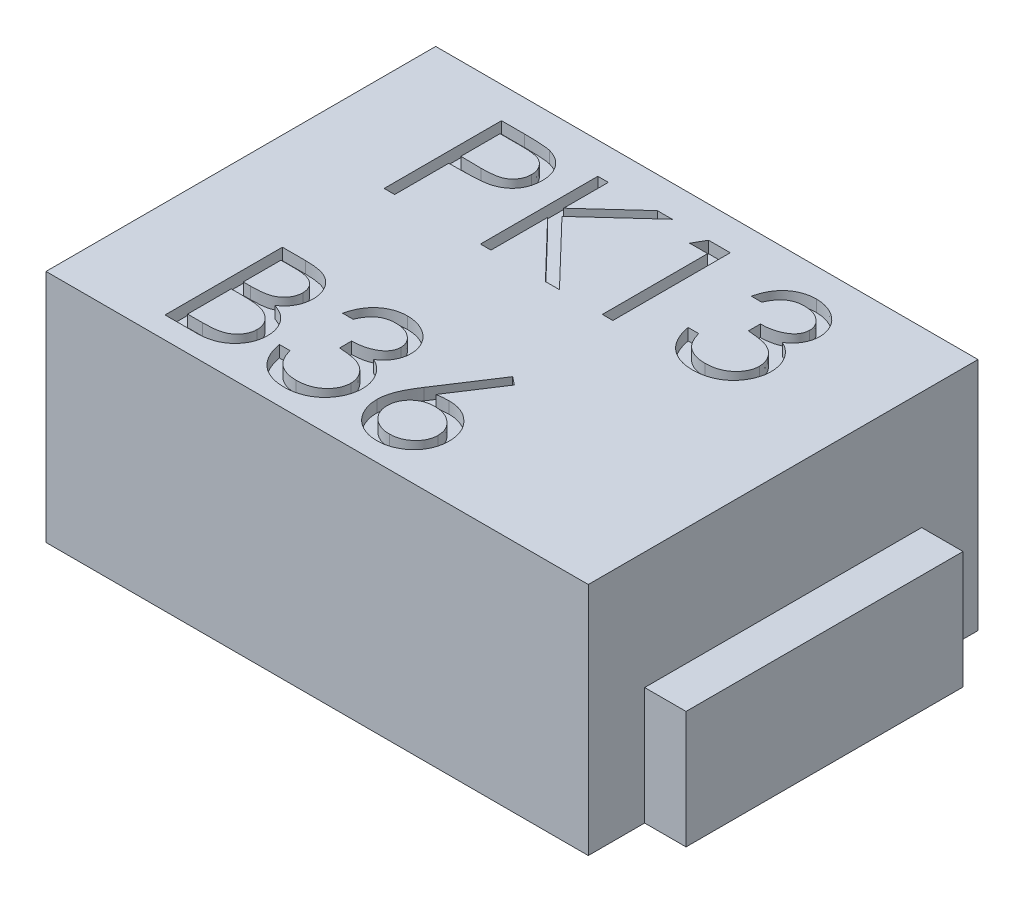
from build123d import *

# Parameters (mm, degrees)
ESQUISSE1_W             = 4.62
ESQUISSE1_H             = 3.32
BOSS_EXTRU_1_DEPTH      = 2
ESQUISSE2_W             = 0.352686225
ESQUISSE2_H             = 2.36
BOSS_EXTRU_2_DEPTH      = 1
ENL_V_MAT_EXTRU_1_DEPTH = 0.1


with BuildPart() as part:
    # Esquisse1 → Boss.-Extru.1 (new body)
    with BuildSketch(Plane(origin=(0, 0, 0), x_dir=(1, 0, 0), z_dir=(0, 1, 0))):
        Rectangle(ESQUISSE1_W, ESQUISSE1_H)
    extrude(amount=BOSS_EXTRU_1_DEPTH)

    # Esquisse2 → Boss.-Extru.2 (add)
    with BuildSketch(Plane.XZ):
        with Locations((-2.486343113, 0)):
            Rectangle(ESQUISSE2_W, ESQUISSE2_H)
    boss_extru_2 = extrude(amount=-BOSS_EXTRU_2_DEPTH)

    # Symétrie1: Boss.-Extru.2 across plane
    add(boss_extru_2.mirror(Plane(origin=(0, 0, 0), x_dir=(0, 0, 1), z_dir=(1, 0, 0))))

    # Esquisse3 → Enlèv. mat.-Extru.1 (cut)
    with BuildSketch(Plane(origin=(0, 2, 0), x_dir=(1, 0, 0), z_dir=(0, 1, 0))):
        with BuildLine():
            Line((-1.481806049, 1.392476034), (-1.285692267, 1.392476034))
            add(Edge.make_bspline(
                [(-1.285692267, 1.392476034), (-1.272203436, 1.392461207), (-1.246358238, 1.392432797), (-1.209296794, 1.391571441), (-1.175636871, 1.390420957), (-1.145451048, 1.388826131), (-1.118646448, 1.386941391), (-1.095344363, 1.384297951), (-1.075361632, 1.381537866), (-1.063388361, 1.37873175), (-1.057927844, 1.377451996)],
                knots=[0, 0, 0, 0, 1.415646017, 2.712440637, 3.8905458, 4.950247383, 5.884950622, 6.709939814, 7.411656543, 8, 8, 8, 8], degree=3))
            add(Edge.make_bspline(
                [(-1.057927844, 1.377451996), (-1.051015405, 1.37556001), (-1.037353412, 1.371820621), (-1.0176674, 1.364330986), (-0.99893773, 1.355450367), (-0.981100141, 1.345329241), (-0.964373832, 1.333533366), (-0.948509249, 1.320540904), (-0.933646397, 1.306051884), (-0.919868857, 1.290228816), (-0.907216057, 1.273337327), (-0.896321862, 1.255125261), (-0.887199798, 1.235899175), (-0.879376006, 1.21567244), (-0.873745019, 1.194275205), (-0.869503047, 1.171856144), (-0.866810582, 1.148417661), (-0.866552708, 1.132400556), (-0.866421433, 1.124246868)],
                knots=[0, 0, 0, 0, 0.999701418, 1.975846123, 2.934577507, 3.890451536, 4.834027766, 5.787354733, 6.749476667, 7.726910423, 8.712836071, 9.690891519, 10.682875813, 11.679750201, 12.712814741, 13.765529915, 14.8625177, 16, 16, 16, 16], degree=3))
            add(Edge.make_bspline(
                [(-0.866421433, 1.124246868), (-0.86654184, 1.116024646), (-0.866777425, 1.099937313), (-0.869604935, 1.076402231), (-0.873413561, 1.053911262), (-0.879269862, 1.032514276), (-0.886940054, 1.012338342), (-0.895937784, 0.993075133), (-0.906790221, 0.975052369), (-0.919260172, 0.958204621), (-0.933132056, 0.942516075), (-0.948347182, 0.92810042), (-0.964844122, 0.915042037), (-0.98257045, 0.903311653), (-1.001698979, 0.893181288), (-1.021939594, 0.884107772), (-1.043468227, 0.876487469), (-1.058366088, 0.87247888), (-1.065940664, 0.870440778)],
                knots=[0, 0, 0, 0, 1.121902311, 2.195077645, 3.232258892, 4.234102512, 5.217864754, 6.176164875, 7.132989551, 8.084763148, 9.034132444, 9.988522005, 10.94243251, 11.903244335, 12.886203696, 13.894208494, 14.929344452, 16, 16, 16, 16], degree=3))
            add(Edge.make_bspline(
                [(-1.065940664, 0.870440778), (-1.072205617, 0.869108498), (-1.085935625, 0.866188728), (-1.108547831, 0.862929169), (-1.134875084, 0.860146997), (-1.16488145, 0.858060958), (-1.198539994, 0.856275138), (-1.235868925, 0.854855683), (-1.276941518, 0.854075725), (-1.305590445, 0.854035498), (-1.320548036, 0.854014496)],
                knots=[0, 0, 0, 0, 0.601384939, 1.31797006, 2.144135048, 3.087295005, 4.142315834, 5.309527816, 6.595305764, 8, 8, 8, 8], degree=3))
            Line((-1.320548036, 0.854014496), (-1.392062459, 0.854014496))
            Line((-1.392062459, 0.854014496), (-1.392062459, 0.392476034))
            Line((-1.392062459, 0.392476034), (-1.481806049, 0.392476034))
            Line((-1.481806049, 0.392476034), (-1.481806049, 1.392476034))
        make_face()
        with BuildLine():
            Line((-1.392062459, 1.289911932), (-1.392062459, 0.956578598))
            Line((-1.392062459, 0.956578598), (-1.216982331, 0.954375073))
            add(Edge.make_bspline(
                [(-1.216982331, 0.954375073), (-1.208433781, 0.954370655), (-1.191930981, 0.954362125), (-1.16809206, 0.955500761), (-1.14597512, 0.956815199), (-1.125648099, 0.958739748), (-1.107101832, 0.961460107), (-1.090305395, 0.964206318), (-1.075389029, 0.968179279), (-1.057932114, 0.973528727), (-1.038479729, 0.982652332), (-1.017317572, 0.995895157), (-0.999383119, 1.01277536), (-0.983863605, 1.03175474), (-0.97154764, 1.052868777), (-0.962531643, 1.075459902), (-0.957234169, 1.09929643), (-0.956523828, 1.115607327), (-0.956165023, 1.123846227)],
                knots=[0, 0, 0, 0, 1.160613943, 2.240541288, 3.23993089, 4.169200891, 5.011653406, 5.7853311, 6.478053781, 7.106038997, 8.262395093, 9.384106736, 10.481365981, 11.59014053, 12.70357646, 13.786202915, 14.881775077, 16, 16, 16, 16], degree=3))
            add(Edge.make_bspline(
                [(-0.956165023, 1.123846227), (-0.956525779, 1.131885802), (-0.957242918, 1.147867482), (-0.962573164, 1.171289985), (-0.971530111, 1.193643044), (-0.983946281, 1.214492497), (-0.999015175, 1.233403584), (-1.016529273, 1.249831334), (-1.036447348, 1.263037535), (-1.054975414, 1.27156133), (-1.071432896, 1.276765694), (-1.085727742, 1.280407077), (-1.101867934, 1.283314393), (-1.119858728, 1.285668537), (-1.139560681, 1.287683812), (-1.161143057, 1.289051234), (-1.184524098, 1.28985165), (-1.200755689, 1.289891351), (-1.209169831, 1.289911932)],
                knots=[0, 0, 0, 0, 1.120700087, 2.227813068, 3.331159281, 4.466773991, 5.599788987, 6.693661531, 7.80175334, 8.91857717, 9.525282508, 10.207424825, 10.974604443, 11.810962634, 12.737642355, 13.736264703, 14.826523623, 16, 16, 16, 16], degree=3))
            Line((-1.209169831, 1.289911932), (-1.392062459, 1.289911932))
        make_face(mode=Mode.SUBTRACT)
        Polygon((-0.661293228, 1.392476034), (-0.571549639, 1.392476034), (-0.571549639, 1.011666739), (-0.154682651, 1.392476034), (-0.026677844, 1.392476034), (-0.518064062, 0.943758086), (0.011783695, 0.392476034), (-0.107807651, 0.392476034), (-0.571549639, 0.87504815), (-0.571549639, 0.392476034), (-0.661293228, 0.392476034), align=None)
        Polygon((0.282016067, 1.392476034), (0.4669119, 1.392476034), (0.4669119, 0.392476034), (0.37716831, 0.392476034), (0.37716831, 1.289911932), (0.223322156, 1.289911932), align=None)
        with BuildLine():
            Line((0.9669119, 1.161706803), (0.87716831, 1.161706803))
            add(Edge.make_bspline(
                [(0.87716831, 1.161706803), (0.87959961, 1.171773227), (0.884352603, 1.191452263), (0.894266196, 1.219568623), (0.905065983, 1.246175344), (0.918034299, 1.270774222), (0.932179657, 1.293859623), (0.948386149, 1.314907944), (0.96590607, 1.334454505), (0.985284626, 1.351801145), (1.005607101, 1.367509067), (1.02715985, 1.380901941), (1.049509248, 1.392423127), (1.072810143, 1.401914622), (1.097131906, 1.409064772), (1.122254656, 1.414252431), (1.148244227, 1.41762132), (1.165886396, 1.41795011), (1.174844592, 1.41811706)],
                knots=[0, 0, 0, 0, 1.162005537, 2.271625781, 3.343758855, 4.383309926, 5.390229558, 6.379919256, 7.361854164, 8.333198761, 9.295911338, 10.242430842, 11.177959212, 12.116337295, 13.062827104, 14.020064771, 14.994644689, 16, 16, 16, 16], degree=3))
            add(Edge.make_bspline(
                [(1.174844592, 1.41811706), (1.187896804, 1.417722994), (1.213716522, 1.416943458), (1.251648821, 1.409825048), (1.288227912, 1.398560724), (1.323053411, 1.382996802), (1.355401535, 1.363800427), (1.384183303, 1.340953359), (1.409008591, 1.314896416), (1.429835556, 1.286115683), (1.446142699, 1.255356966), (1.458167377, 1.223699779), (1.465487857, 1.191219215), (1.466436588, 1.169288564), (1.4669119, 1.158301355)],
                knots=[0, 0, 0, 0, 1.083050992, 2.142477498, 3.193116406, 4.255571735, 5.30263384, 6.308962982, 7.297363603, 8.282367274, 9.249857812, 10.179914175, 11.08814088, 12, 12, 12, 12], degree=3))
            add(Edge.make_bspline(
                [(1.4669119, 1.158301355), (1.466579445, 1.147727985), (1.465928883, 1.127037541), (1.460404967, 1.096831399), (1.451108892, 1.06836237), (1.438231817, 1.041510609), (1.421562803, 1.016446369), (1.401370604, 0.993113258), (1.3775127, 0.971407784), (1.359433004, 0.958973649), (1.350125041, 0.952572188)],
                knots=[0, 0, 0, 0, 1.024540389, 2.004866551, 2.965041327, 3.920577974, 4.882998113, 5.874504559, 6.905732034, 8, 8, 8, 8], degree=3))
            add(Edge.make_bspline(
                [(1.350125041, 0.952572188), (1.360762685, 0.947435568), (1.381838935, 0.937258437), (1.410567658, 0.917299649), (1.436647051, 0.894254978), (1.45119097, 0.876271363), (1.458498438, 0.86723565)],
                knots=[0, 0, 0, 0, 1.015518401, 2.012035669, 3.001164323, 4, 4, 4, 4], degree=3))
            add(Edge.make_bspline(
                [(1.458498438, 0.86723565), (1.46331025, 0.860647721), (1.472855078, 0.847579744), (1.484636659, 0.826569337), (1.495324977, 0.805326054), (1.503653611, 0.78328051), (1.510103288, 0.76068822), (1.514713583, 0.737510393), (1.517577623, 0.713728101), (1.517987781, 0.697638821), (1.518193951, 0.689551355)],
                knots=[0, 0, 0, 0, 1.025084078, 2.033381695, 3.024893161, 4.013698104, 4.991890475, 5.976764909, 6.982997093, 8, 8, 8, 8], degree=3))
            add(Edge.make_bspline(
                [(1.518193951, 0.689551355), (1.517681233, 0.675548577), (1.51665821, 0.64760892), (1.507514188, 0.606330428), (1.493338977, 0.565980284), (1.473208424, 0.527387473), (1.44867485, 0.491278793), (1.419487043, 0.458971276), (1.38597664, 0.431200246), (1.348603598, 0.407997324), (1.30811299, 0.389449346), (1.264805678, 0.376575791), (1.219305662, 0.36819122), (1.188103577, 0.367292114), (1.172240426, 0.366835009)],
                knots=[0, 0, 0, 0, 0.955779014, 1.907060117, 2.875433937, 3.871313158, 4.872415639, 5.851225146, 6.836215519, 7.83643374, 8.849228613, 9.86973379, 10.916971861, 12, 12, 12, 12], degree=3))
            add(Edge.make_bspline(
                [(1.172240426, 0.366835009), (1.161549197, 0.36708307), (1.140512424, 0.367571171), (1.10958571, 0.370907914), (1.080065225, 0.377002201), (1.051911054, 0.385203146), (1.025098186, 0.395600786), (0.999708442, 0.408548986), (0.975585615, 0.423780843), (0.952957343, 0.441476154), (0.931826324, 0.461270823), (0.912754117, 0.483516254), (0.895422748, 0.507801227), (0.88029628, 0.534407814), (0.866685722, 0.562992173), (0.855491163, 0.593920316), (0.845638143, 0.626915751), (0.841057153, 0.649909391), (0.838706772, 0.661706803)],
                knots=[0, 0, 0, 0, 1.048658725, 2.063410685, 3.046034179, 4.001477787, 4.936774919, 5.862367409, 6.792675028, 7.730719943, 8.675894397, 9.627829632, 10.600096036, 11.597688215, 12.626045268, 13.701542398, 14.82072376, 16, 16, 16, 16], degree=3))
            Line((0.838706772, 0.661706803), (0.928450361, 0.661706803))
            add(Edge.make_bspline(
                [(0.928450361, 0.661706803), (0.930788445, 0.654007085), (0.93533622, 0.639030465), (0.943077448, 0.617476092), (0.951896954, 0.597716648), (0.961358257, 0.579607185), (0.971294955, 0.562969355), (0.982413505, 0.548243107), (0.993890404, 0.534781621), (1.002541648, 0.527197446), (1.006775682, 0.52348565)],
                knots=[0, 0, 0, 0, 1.198163088, 2.33053128, 3.407730985, 4.417276592, 5.372219308, 6.28897303, 7.162600585, 8, 8, 8, 8], degree=3))
            add(Edge.make_bspline(
                [(1.006775682, 0.52348565), (1.012374704, 0.519168983), (1.023555465, 0.510548974), (1.041774959, 0.499548508), (1.060936355, 0.490016787), (1.081454834, 0.482735731), (1.102887625, 0.476570685), (1.125581158, 0.472536251), (1.14933522, 0.469768202), (1.165554581, 0.469523936), (1.17384299, 0.469399111)],
                knots=[0, 0, 0, 0, 0.946170439, 1.889420265, 2.845303464, 3.807233317, 4.801018734, 5.828864929, 6.890507805, 8, 8, 8, 8], degree=3))
            add(Edge.make_bspline(
                [(1.17384299, 0.469399111), (1.183201133, 0.469575084), (1.201500175, 0.469919184), (1.228201564, 0.473083672), (1.253603692, 0.477692361), (1.277424527, 0.484810356), (1.299976101, 0.493604885), (1.320942287, 0.504647287), (1.340598317, 0.517602922), (1.358692433, 0.532328395), (1.374962578, 0.548448823), (1.389288153, 0.5653097), (1.401466628, 0.582839937), (1.411290507, 0.601136543), (1.419047807, 0.620123751), (1.424328722, 0.639854845), (1.428000583, 0.66016835), (1.428299615, 0.673976627), (1.428450361, 0.680937573)],
                knots=[0, 0, 0, 0, 1.217147791, 2.380027433, 3.494444702, 4.572153297, 5.609568379, 6.639424714, 7.649109417, 8.668170816, 9.669597737, 10.625200337, 11.543417969, 12.441394052, 13.322311151, 14.205496177, 15.095365482, 16, 16, 16, 16], degree=3))
            add(Edge.make_bspline(
                [(1.428450361, 0.680937573), (1.428013132, 0.690255098), (1.42714085, 0.708843786), (1.420481256, 0.736191665), (1.409527295, 0.762541211), (1.394192291, 0.787442865), (1.37552494, 0.810521694), (1.353706396, 0.831113546), (1.328555473, 0.848105001), (1.305406939, 0.859844617), (1.284902609, 0.86785521), (1.267355356, 0.873190914), (1.247710612, 0.877709101), (1.226205941, 0.881912608), (1.202679308, 0.885490136), (1.177156326, 0.888473512), (1.149631822, 0.890860666), (1.130577203, 0.891926693), (1.120758054, 0.892476034)],
                knots=[0, 0, 0, 0, 1.07054697, 2.135767047, 3.216561865, 4.33974944, 5.486079747, 6.621378074, 7.775625952, 8.963672916, 9.598146892, 10.304877434, 11.070270905, 11.915000392, 12.823868403, 13.805723172, 14.86925407, 16, 16, 16, 16], degree=3))
            Line((1.120758054, 0.892476034), (1.120758054, 0.995040137))
            add(Edge.make_bspline(
                [(1.120758054, 0.995040137), (1.133129815, 0.995250081), (1.157363057, 0.995661309), (1.19276143, 1.000635027), (1.226610948, 1.007515206), (1.258161446, 1.018053832), (1.286918221, 1.030293917), (1.311866679, 1.044537406), (1.332657292, 1.060370191), (1.349189027, 1.078036651), (1.361625949, 1.096983807), (1.37071932, 1.116731424), (1.376090842, 1.137452584), (1.376807889, 1.151593918), (1.37716831, 1.158701996)],
                knots=[0, 0, 0, 0, 1.321986639, 2.589447074, 3.816329219, 5.01088745, 6.139805852, 7.153945165, 8.075214402, 8.924034688, 9.728124013, 10.488707548, 11.240355623, 12, 12, 12, 12], degree=3))
            add(Edge.make_bspline(
                [(1.37716831, 1.158701996), (1.377049907, 1.163924209), (1.37681435, 1.174313554), (1.373843699, 1.189492145), (1.369379687, 1.204206701), (1.363242622, 1.218394646), (1.355028279, 1.231957582), (1.345197997, 1.245011139), (1.333492826, 1.25748079), (1.320079841, 1.269103738), (1.305676468, 1.280180663), (1.289890818, 1.289584559), (1.273198854, 1.297626006), (1.255582095, 1.304257292), (1.236983372, 1.30924566), (1.21749007, 1.312827329), (1.197065018, 1.315066659), (1.183130237, 1.315389064), (1.176046515, 1.315552957)],
                knots=[0, 0, 0, 0, 0.884392785, 1.759457502, 2.611959086, 3.489218968, 4.37281399, 5.2945488, 6.255912374, 7.266815255, 8.301784654, 9.332968512, 10.37626691, 11.440494194, 12.520033166, 13.637162961, 14.798855837, 16, 16, 16, 16], degree=3))
            add(Edge.make_bspline(
                [(1.176046515, 1.315552957), (1.164660324, 1.315155425), (1.142420445, 1.314378953), (1.110359041, 1.307578092), (1.080553517, 1.296727211), (1.05777104, 1.28377492), (1.040947448, 1.270989081), (1.028925466, 1.259822685), (1.017119605, 1.247413307), (1.006306555, 1.232996628), (0.995371133, 1.217548974), (0.985415544, 1.200285065), (0.975741346, 1.181655238), (0.969912046, 1.168485057), (0.9669119, 1.161706803)],
                knots=[0, 0, 0, 0, 1.472543308, 2.876219568, 4.221790263, 5.565193594, 6.249813518, 6.953379497, 7.687249741, 8.463570142, 9.283606569, 10.136032583, 11.040678096, 12, 12, 12, 12], degree=3))
        make_face()
        with BuildLine():
            Line((-1.481806049, -0.474190632), (-1.286693869, -0.474190632))
            add(Edge.make_bspline(
                [(-1.286693869, -0.474190632), (-1.277142876, -0.474240847), (-1.258630673, -0.474338175), (-1.231710832, -0.475847641), (-1.206496886, -0.477905832), (-1.182981523, -0.481171573), (-1.161175608, -0.485112081), (-1.141013426, -0.489884028), (-1.122559091, -0.495605918), (-1.10052688, -0.504704855), (-1.075406691, -0.518225761), (-1.048207151, -0.538205351), (-1.024948797, -0.562643197), (-1.004895563, -0.59020967), (-0.988952386, -0.620534176), (-0.977418301, -0.652893945), (-0.970116051, -0.686871585), (-0.96936507, -0.710198207), (-0.968985536, -0.721987107)],
                knots=[0, 0, 0, 0, 1.001505555, 1.941167018, 2.826882275, 3.653841531, 4.429895133, 5.150066043, 5.825578002, 6.45369114, 7.647487171, 8.808567382, 9.977351308, 11.170798116, 12.373658725, 13.556498008, 14.765093433, 16, 16, 16, 16], degree=3))
            add(Edge.make_bspline(
                [(-0.968985536, -0.721987107), (-0.969297884, -0.733030694), (-0.969911678, -0.754732385), (-0.975781037, -0.786473559), (-0.9849698, -0.816688193), (-0.997742728, -0.845266017), (-1.014343299, -0.871561335), (-1.034017104, -0.895786268), (-1.057753333, -0.916915142), (-1.075537116, -0.9287274), (-1.084570472, -0.934727491)],
                knots=[0, 0, 0, 0, 1.044552857, 2.05264487, 3.044412934, 4.028983338, 5.005914585, 5.980388656, 6.974128949, 8, 8, 8, 8], degree=3))
            add(Edge.make_bspline(
                [(-1.084570472, -0.934727491), (-1.07321035, -0.93908892), (-1.051475622, -0.947433412), (-1.021565333, -0.962186402), (-0.995795377, -0.978232719), (-0.973967621, -0.995756105), (-0.95529972, -1.014644337), (-0.938998879, -1.035174369), (-0.925089915, -1.057614014), (-0.913171937, -1.08172931), (-0.903872292, -1.107274016), (-0.896907748, -1.134008523), (-0.892917048, -1.161836967), (-0.892349151, -1.180775647), (-0.892062459, -1.190336466)],
                knots=[0, 0, 0, 0, 1.27268992, 2.434971085, 3.483601985, 4.442670788, 5.356604649, 6.2567628, 7.179492994, 8.113709626, 9.066344395, 10.018646069, 10.999752585, 12, 12, 12, 12], degree=3))
            add(Edge.make_bspline(
                [(-0.892062459, -1.190336466), (-0.892341558, -1.200098429), (-0.892890693, -1.219305366), (-0.896942113, -1.247521119), (-0.903801858, -1.274485389), (-0.913250757, -1.300372584), (-0.925582847, -1.325132622), (-0.940590837, -1.348793555), (-0.958485569, -1.37111765), (-0.978503532, -1.39235297), (-1.001149859, -1.411446624), (-1.025582932, -1.428451112), (-1.052110452, -1.442435701), (-1.080296736, -1.454183135), (-1.110457969, -1.463156621), (-1.142458714, -1.469434499), (-1.176271372, -1.47366451), (-1.199474158, -1.474012282), (-1.211373356, -1.474190632)],
                knots=[0, 0, 0, 0, 0.978564426, 1.925352924, 2.850884081, 3.763762016, 4.682927383, 5.618979971, 6.567305752, 7.547517671, 8.540179244, 9.531824382, 10.526200242, 11.540722885, 12.589160233, 13.674978461, 14.80764778, 16, 16, 16, 16], degree=3))
            Line((-1.211373356, -1.474190632), (-1.481806049, -1.474190632))
            Line((-1.481806049, -1.474190632), (-1.481806049, -0.474190632))
        make_face()
        with BuildLine():
            Line((-1.392062459, -0.576754735), (-1.392062459, -0.897267555))
            Line((-1.392062459, -0.897267555), (-1.331765985, -0.897267555))
            add(Edge.make_bspline(
                [(-1.331765985, -0.897267555), (-1.322952043, -0.897153292), (-1.305921712, -0.896932511), (-1.281258884, -0.896300078), (-1.258366022, -0.894529208), (-1.237282641, -0.892758847), (-1.218041943, -0.889880394), (-1.200686554, -0.886454073), (-1.184944098, -0.882830386), (-1.166789942, -0.876667675), (-1.146197671, -0.867559768), (-1.124245355, -0.853424958), (-1.10489265, -0.836589428), (-1.088550596, -0.817163439), (-1.07517589, -0.7957731), (-1.065886257, -0.772759706), (-1.059587033, -0.748696811), (-1.059018024, -0.73217731), (-1.058729126, -0.723789991)],
                knots=[0, 0, 0, 0, 1.156816544, 2.235205308, 3.236616184, 4.169592532, 5.011045266, 5.787822928, 6.49130361, 7.128639758, 8.301311294, 9.436451833, 10.541879658, 11.654887649, 12.756523258, 13.837046038, 14.901820046, 16, 16, 16, 16], degree=3))
            add(Edge.make_bspline(
                [(-1.058729126, -0.723789991), (-1.058879463, -0.718239771), (-1.059174366, -0.707352407), (-1.061589595, -0.691481163), (-1.065694616, -0.676554377), (-1.070967272, -0.662367488), (-1.078335468, -0.649364103), (-1.087010744, -0.637094618), (-1.097492369, -0.62597687), (-1.10942303, -0.615585585), (-1.123139779, -0.606372862), (-1.138634434, -0.598304073), (-1.156116628, -0.591806708), (-1.175291729, -0.586116379), (-1.196454897, -0.582119724), (-1.219361912, -0.578790184), (-1.244200403, -0.577095115), (-1.261384718, -0.576870726), (-1.270267587, -0.576754735)],
                knots=[0, 0, 0, 0, 0.91205012, 1.789085906, 2.630437955, 3.453916878, 4.269457761, 5.079663411, 5.91843418, 6.774407191, 7.675494373, 8.627863946, 9.638891023, 10.736472738, 11.911756761, 13.175263542, 14.539845004, 16, 16, 16, 16], degree=3))
            Line((-1.270267587, -0.576754735), (-1.392062459, -0.576754735))
        make_face(mode=Mode.SUBTRACT)
        with BuildLine():
            Line((-1.392062459, -0.999831658), (-1.392062459, -1.37162653))
            Line((-1.392062459, -1.37162653), (-1.264257972, -1.37162653))
            add(Edge.make_bspline(
                [(-1.264257972, -1.37162653), (-1.255109707, -1.371516888), (-1.237477633, -1.371305567), (-1.212020139, -1.370615694), (-1.188424967, -1.369046473), (-1.166799785, -1.36657623), (-1.146911084, -1.363896673), (-1.128997455, -1.36029345), (-1.112913685, -1.356165175), (-1.094263883, -1.349783983), (-1.073262881, -1.339870706), (-1.050631207, -1.324923784), (-1.030509431, -1.307117125), (-1.013422214, -1.286508292), (-0.999418503, -1.264099342), (-0.98923123, -1.240343527), (-0.982948128, -1.215633377), (-0.982187508, -1.198785744), (-0.981806049, -1.190336466)],
                knots=[0, 0, 0, 0, 1.160039823, 2.235823828, 3.228722157, 4.157150951, 4.99529583, 5.772374946, 6.472645482, 7.099169577, 8.269452708, 9.405989375, 10.527446681, 11.663510218, 12.788923519, 13.866172445, 14.929861265, 16, 16, 16, 16], degree=3))
            add(Edge.make_bspline(
                [(-0.981806049, -1.190336466), (-0.981884936, -1.185052654), (-0.982041437, -1.174570259), (-0.984401613, -1.15916574), (-0.987834147, -1.144244062), (-0.9922717, -1.129764707), (-0.998734405, -1.115989457), (-1.006279132, -1.102645868), (-1.015125246, -1.089716303), (-1.028909294, -1.073369945), (-1.048958432, -1.054536512), (-1.077446082, -1.036097226), (-1.109838168, -1.021226424), (-1.133331737, -1.014912288), (-1.145467908, -1.011650568)],
                knots=[0, 0, 0, 0, 0.723448775, 1.435228256, 2.130040452, 2.821711965, 3.505591119, 4.210454504, 4.921174351, 5.648778258, 7.137944449, 8.670945889, 10.280296675, 12, 12, 12, 12], degree=3))
            add(Edge.make_bspline(
                [(-1.145467908, -1.011650568), (-1.150333364, -1.010663401), (-1.160882676, -1.00852302), (-1.178084842, -1.006263676), (-1.197723661, -1.004250802), (-1.219844483, -1.0027619), (-1.244475295, -1.001222887), (-1.271668701, -1.000624367), (-1.301313648, -0.999910293), (-1.321882897, -0.99985854), (-1.332567267, -0.999831658)],
                knots=[0, 0, 0, 0, 0.634451884, 1.375622551, 2.216452059, 3.157844607, 4.20941857, 5.370758133, 6.634282058, 8, 8, 8, 8], degree=3))
            Line((-1.332567267, -0.999831658), (-1.392062459, -0.999831658))
        make_face(mode=Mode.SUBTRACT)
        with BuildLine():
            Line((-0.648472715, -0.704959863), (-0.738216305, -0.704959863))
            add(Edge.make_bspline(
                [(-0.738216305, -0.704959863), (-0.735785005, -0.694893439), (-0.731032012, -0.675214404), (-0.72111842, -0.647098043), (-0.710318632, -0.620491323), (-0.697350317, -0.595892445), (-0.683204958, -0.572807044), (-0.666998467, -0.551758723), (-0.649478546, -0.532212161), (-0.630099989, -0.514865522), (-0.609777514, -0.499157599), (-0.588224766, -0.485764726), (-0.565875367, -0.474243539), (-0.542574472, -0.464752044), (-0.518252709, -0.457601895), (-0.493129959, -0.452414236), (-0.467140388, -0.449045346), (-0.449498219, -0.448716557), (-0.440540023, -0.448549607)],
                knots=[0, 0, 0, 0, 1.162005537, 2.271625781, 3.343758855, 4.383309926, 5.390229558, 6.379919256, 7.361854164, 8.333198761, 9.295911338, 10.242430842, 11.177959212, 12.116337295, 13.062827104, 14.020064771, 14.994644689, 16, 16, 16, 16], degree=3))
            add(Edge.make_bspline(
                [(-0.440540023, -0.448549607), (-0.427487811, -0.448943673), (-0.401668094, -0.449723208), (-0.363735795, -0.456841619), (-0.327156703, -0.468105942), (-0.292331204, -0.483669864), (-0.25998308, -0.50286624), (-0.231201313, -0.525713307), (-0.206376024, -0.551770251), (-0.185549059, -0.580550983), (-0.169241916, -0.6113097), (-0.157217238, -0.642966888), (-0.149896758, -0.675447451), (-0.148948027, -0.697378102), (-0.148472715, -0.708365312)],
                knots=[0, 0, 0, 0, 1.083050992, 2.142477498, 3.193116406, 4.255571735, 5.30263384, 6.308962982, 7.297363603, 8.282367274, 9.249857812, 10.179914175, 11.08814088, 12, 12, 12, 12], degree=3))
            add(Edge.make_bspline(
                [(-0.148472715, -0.708365312), (-0.14880517, -0.718938682), (-0.149455732, -0.739629126), (-0.154979648, -0.769835268), (-0.164275723, -0.798304297), (-0.177152798, -0.825156057), (-0.193821812, -0.850220297), (-0.214014012, -0.873553409), (-0.237871915, -0.895258883), (-0.255951612, -0.907693018), (-0.265259574, -0.914094479)],
                knots=[0, 0, 0, 0, 1.024540389, 2.004866551, 2.965041327, 3.920577974, 4.882998113, 5.874504559, 6.905732034, 8, 8, 8, 8], degree=3))
            add(Edge.make_bspline(
                [(-0.265259574, -0.914094479), (-0.25462193, -0.919231099), (-0.23354568, -0.92940823), (-0.204816958, -0.949367018), (-0.178737565, -0.972411688), (-0.164193645, -0.990395303), (-0.156886177, -0.999431017)],
                knots=[0, 0, 0, 0, 1.015518401, 2.012035669, 3.001164323, 4, 4, 4, 4], degree=3))
            add(Edge.make_bspline(
                [(-0.156886177, -0.999431017), (-0.152074365, -1.006018946), (-0.142529537, -1.019086922), (-0.130747956, -1.04009733), (-0.120059638, -1.061340612), (-0.111731004, -1.083386157), (-0.105281328, -1.105978446), (-0.100671033, -1.129156274), (-0.097806993, -1.152938566), (-0.097396835, -1.169027846), (-0.097190664, -1.177115312)],
                knots=[0, 0, 0, 0, 1.025084078, 2.033381695, 3.024893161, 4.013698104, 4.991890475, 5.976764909, 6.982997093, 8, 8, 8, 8], degree=3))
            add(Edge.make_bspline(
                [(-0.097190664, -1.177115312), (-0.097703382, -1.191118089), (-0.098726406, -1.219057747), (-0.107870427, -1.260336239), (-0.122045639, -1.300686382), (-0.142176192, -1.339279194), (-0.166709766, -1.375387874), (-0.195897573, -1.407695391), (-0.229407975, -1.435466421), (-0.266781018, -1.458669343), (-0.307271626, -1.477217321), (-0.350578938, -1.490090876), (-0.396078953, -1.498475447), (-0.427281038, -1.499374553), (-0.44314419, -1.499831658)],
                knots=[0, 0, 0, 0, 0.955779014, 1.907060117, 2.875433937, 3.871313158, 4.872415639, 5.851225146, 6.836215519, 7.83643374, 8.849228613, 9.86973379, 10.916971861, 12, 12, 12, 12], degree=3))
            add(Edge.make_bspline(
                [(-0.44314419, -1.499831658), (-0.453835418, -1.499583597), (-0.474872191, -1.499095496), (-0.505798905, -1.495758753), (-0.535319391, -1.489664466), (-0.563473562, -1.481463521), (-0.590286429, -1.471065881), (-0.615676173, -1.458117681), (-0.639799, -1.442885823), (-0.662427272, -1.425190513), (-0.683558291, -1.405395844), (-0.702630498, -1.383150413), (-0.719961868, -1.35886544), (-0.735088336, -1.332258853), (-0.748698894, -1.303674493), (-0.759893453, -1.272746351), (-0.769746472, -1.239750916), (-0.774327462, -1.216757276), (-0.776677844, -1.204959863)],
                knots=[0, 0, 0, 0, 1.048658725, 2.063410685, 3.046034179, 4.001477787, 4.936774919, 5.862367409, 6.792675028, 7.730719943, 8.675894397, 9.627829632, 10.600096036, 11.597688215, 12.626045268, 13.701542398, 14.82072376, 16, 16, 16, 16], degree=3))
            Line((-0.776677844, -1.204959863), (-0.686934254, -1.204959863))
            add(Edge.make_bspline(
                [(-0.686934254, -1.204959863), (-0.684596171, -1.212659581), (-0.680048396, -1.227636202), (-0.672307168, -1.249190575), (-0.663487661, -1.268950019), (-0.654026359, -1.287059482), (-0.64408966, -1.303697311), (-0.63297111, -1.31842356), (-0.621494211, -1.331885046), (-0.612842968, -1.339469221), (-0.608608933, -1.343181017)],
                knots=[0, 0, 0, 0, 1.198163088, 2.33053128, 3.407730985, 4.417276592, 5.372219308, 6.28897303, 7.162600585, 8, 8, 8, 8], degree=3))
            add(Edge.make_bspline(
                [(-0.608608933, -1.343181017), (-0.603009912, -1.347497684), (-0.591829151, -1.356117693), (-0.573609656, -1.367118158), (-0.55444826, -1.37664988), (-0.533929782, -1.383930936), (-0.51249699, -1.390095982), (-0.489803457, -1.394130416), (-0.466049395, -1.396898465), (-0.449830034, -1.397142731), (-0.441541626, -1.397267555)],
                knots=[0, 0, 0, 0, 0.946170439, 1.889420265, 2.845303464, 3.807233317, 4.801018734, 5.828864929, 6.890507805, 8, 8, 8, 8], degree=3))
            add(Edge.make_bspline(
                [(-0.441541626, -1.397267555), (-0.432183482, -1.397091583), (-0.41388444, -1.396747483), (-0.387183052, -1.393582995), (-0.361780924, -1.388974305), (-0.337960088, -1.38185631), (-0.315408514, -1.373061781), (-0.294442329, -1.36201938), (-0.274786298, -1.349063745), (-0.256692183, -1.334338271), (-0.240422038, -1.318217844), (-0.226096462, -1.301356967), (-0.213917988, -1.28382673), (-0.204094108, -1.265530124), (-0.196336808, -1.246542915), (-0.191055894, -1.226811821), (-0.187384032, -1.206498317), (-0.187085, -1.19269004), (-0.186934254, -1.185729094)],
                knots=[0, 0, 0, 0, 1.217147791, 2.380027433, 3.494444702, 4.572153297, 5.609568379, 6.639424714, 7.649109417, 8.668170816, 9.669597737, 10.625200337, 11.543417969, 12.441394052, 13.322311151, 14.205496177, 15.095365482, 16, 16, 16, 16], degree=3))
            add(Edge.make_bspline(
                [(-0.186934254, -1.185729094), (-0.187371483, -1.176411569), (-0.188243765, -1.15782288), (-0.194903359, -1.130475002), (-0.205857321, -1.104125456), (-0.221192324, -1.079223801), (-0.239859675, -1.056144972), (-0.26167822, -1.03555312), (-0.286829142, -1.018561666), (-0.309977676, -1.00682205), (-0.330482007, -0.998811457), (-0.348029259, -0.993475753), (-0.367674003, -0.988957565), (-0.389178674, -0.984754059), (-0.412705308, -0.981176531), (-0.43822829, -0.978193155), (-0.465752793, -0.975806001), (-0.484807412, -0.974739973), (-0.494626562, -0.974190632)],
                knots=[0, 0, 0, 0, 1.07054697, 2.135767047, 3.216561865, 4.33974944, 5.486079747, 6.621378074, 7.775625952, 8.963672916, 9.598146892, 10.304877434, 11.070270905, 11.915000392, 12.823868403, 13.805723172, 14.86925407, 16, 16, 16, 16], degree=3))
            Line((-0.494626562, -0.974190632), (-0.494626562, -0.87162653))
            add(Edge.make_bspline(
                [(-0.494626562, -0.87162653), (-0.4822548, -0.871416586), (-0.458021558, -0.871005357), (-0.422623185, -0.86603164), (-0.388773668, -0.859151461), (-0.35722317, -0.848612834), (-0.328466395, -0.836372749), (-0.303517937, -0.822129261), (-0.282727323, -0.806296476), (-0.266195589, -0.788630016), (-0.253758666, -0.769682859), (-0.244665295, -0.749935243), (-0.239293774, -0.729214083), (-0.238576726, -0.715072749), (-0.238216305, -0.707964671)],
                knots=[0, 0, 0, 0, 1.321986639, 2.589447074, 3.816329219, 5.01088745, 6.139805852, 7.153945165, 8.075214402, 8.924034688, 9.728124013, 10.488707548, 11.240355623, 12, 12, 12, 12], degree=3))
            add(Edge.make_bspline(
                [(-0.238216305, -0.707964671), (-0.238334708, -0.702742458), (-0.238570266, -0.692353113), (-0.241540917, -0.677174522), (-0.246004928, -0.662459966), (-0.252141994, -0.64827202), (-0.260356336, -0.634709085), (-0.270186618, -0.621655528), (-0.28189179, -0.609185877), (-0.295304775, -0.597562928), (-0.309708147, -0.586486004), (-0.325493797, -0.577082107), (-0.342185762, -0.569040661), (-0.35980252, -0.562409375), (-0.378401243, -0.557421007), (-0.397894545, -0.553839338), (-0.418319598, -0.551600008), (-0.432254378, -0.551277603), (-0.4393381, -0.551113709)],
                knots=[0, 0, 0, 0, 0.884392785, 1.759457502, 2.611959086, 3.489218968, 4.37281399, 5.2945488, 6.255912374, 7.266815255, 8.301784654, 9.332968512, 10.37626691, 11.440494194, 12.520033166, 13.637162961, 14.798855837, 16, 16, 16, 16], degree=3))
            add(Edge.make_bspline(
                [(-0.4393381, -0.551113709), (-0.450724291, -0.551511241), (-0.47296417, -0.552287714), (-0.505025575, -0.559088575), (-0.534831099, -0.569939456), (-0.557613575, -0.582891747), (-0.574437168, -0.595677585), (-0.58645915, -0.606843981), (-0.59826501, -0.61925336), (-0.609078061, -0.633670038), (-0.620013482, -0.649117693), (-0.629969071, -0.666381602), (-0.639643269, -0.685011429), (-0.645472569, -0.69818161), (-0.648472715, -0.704959863)],
                knots=[0, 0, 0, 0, 1.472543308, 2.876219568, 4.221790263, 5.565193594, 6.249813518, 6.953379497, 7.687249741, 8.463570142, 9.283606569, 10.136032583, 11.040678096, 12, 12, 12, 12], degree=3))
        make_face()
        with BuildLine():
            Line((0.454091387, -0.448549607), (0.523201964, -0.502836466))
            Line((0.523201964, -0.502836466), (0.258979208, -0.90688294))
            add(Edge.make_bspline(
                [(0.258979208, -0.90688294), (0.276570715, -0.90407898), (0.31088494, -0.898609539), (0.345618054, -0.897707268), (0.362544913, -0.897267555)],
                knots=[0, 0, 0, 0, 1.025318673, 2, 2, 2, 2], degree=3))
            add(Edge.make_bspline(
                [(0.362544913, -0.897267555), (0.372708483, -0.89754073), (0.392715169, -0.898078467), (0.422088541, -0.90221671), (0.450313951, -0.90873817), (0.477274412, -0.918244529), (0.503066692, -0.930388059), (0.527838806, -0.944942022), (0.551125094, -0.962657931), (0.573225431, -0.982447918), (0.593290316, -1.004367056), (0.611054903, -1.027624581), (0.625976844, -1.052196261), (0.638083679, -1.078069652), (0.647485073, -1.105204869), (0.654338685, -1.133567194), (0.658389998, -1.163176186), (0.658940138, -1.183312808), (0.659219592, -1.193541594)],
                knots=[0, 0, 0, 0, 1.04369286, 2.054478336, 3.041073146, 4.015093852, 4.984733326, 5.965804835, 6.960378782, 7.985147595, 9.009457201, 10.008161701, 10.986880575, 11.956520048, 12.937015923, 13.931873656, 14.949455224, 16, 16, 16, 16], degree=3))
            add(Edge.make_bspline(
                [(0.659219592, -1.193541594), (0.658812991, -1.207535795), (0.658012896, -1.235073071), (0.650040382, -1.275180701), (0.637651912, -1.313389992), (0.619944047, -1.349090898), (0.597949081, -1.382234489), (0.571126911, -1.411601765), (0.540428772, -1.437793204), (0.505718258, -1.459695095), (0.468363125, -1.477581681), (0.429119698, -1.490428893), (0.388369084, -1.498338456), (0.360710625, -1.499330057), (0.346719592, -1.499831658)],
                knots=[0, 0, 0, 0, 1.031375318, 2.029502543, 3.004789286, 3.987476834, 4.960371455, 5.9300674, 6.912260825, 7.929083631, 8.949397511, 9.960523116, 10.96833055, 12, 12, 12, 12], degree=3))
            add(Edge.make_bspline(
                [(0.346719592, -1.499831658), (0.333263392, -1.499395028), (0.306609015, -1.49853014), (0.267399646, -1.490825586), (0.229724498, -1.478337843), (0.193847532, -1.461133763), (0.160613071, -1.439402939), (0.130880032, -1.413242288), (0.104796668, -1.383211012), (0.083089633, -1.34931377), (0.065872853, -1.312888068), (0.052961446, -1.274906023), (0.045419662, -1.235506029), (0.044365788, -1.208797132), (0.043834977, -1.195344479)],
                knots=[0, 0, 0, 0, 1.012016664, 2.004627821, 2.994792927, 3.992885782, 4.990978636, 5.973936114, 6.964471063, 7.975201453, 8.993600317, 9.990122807, 10.98767138, 12, 12, 12, 12], degree=3))
            add(Edge.make_bspline(
                [(0.043834977, -1.195344479), (0.044172533, -1.185046026), (0.044861757, -1.164018554), (0.049674154, -1.132171689), (0.057406953, -1.099585666), (0.066067023, -1.07194161), (0.075217197, -1.049295461), (0.082832209, -1.031037321), (0.092310493, -1.012248443), (0.102417173, -0.992284547), (0.114061993, -0.971660138), (0.126723607, -0.950030518), (0.140752079, -0.927739681), (0.150586411, -0.912612768), (0.155613823, -0.904879735)],
                knots=[0, 0, 0, 0, 1.173818275, 2.396712641, 3.66331629, 4.989737886, 5.693666774, 6.447286557, 7.243889047, 8.091586357, 8.998013824, 9.943181721, 10.948533338, 12, 12, 12, 12], degree=3))
            Line((0.155613823, -0.904879735), (0.454091387, -0.448549607))
        make_face()
        with BuildLine():
            add(Edge.make_bspline(
                [(0.343714785, -0.999831658), (0.336097, -1.000053956), (0.321217255, -1.000488169), (0.299386565, -1.00300967), (0.278725636, -1.007757974), (0.258960741, -1.013805498), (0.240461397, -1.022120658), (0.223093157, -1.032221172), (0.206788856, -1.044112937), (0.19171927, -1.057627483), (0.178056509, -1.072424064), (0.166290472, -1.088272499), (0.156141215, -1.104790842), (0.147889266, -1.122117111), (0.14146353, -1.140244683), (0.136815459, -1.159090183), (0.134228673, -1.178779984), (0.133798321, -1.192132128), (0.133578567, -1.198950248)],
                knots=[0, 0, 0, 0, 1.129588631, 2.206414736, 3.251139165, 4.268635594, 5.265702196, 6.250456724, 7.242448911, 8.251968645, 9.246821453, 10.222880186, 11.173611482, 12.116736599, 13.062300278, 14.020270554, 14.989073742, 16, 16, 16, 16], degree=3))
            add(Edge.make_bspline(
                [(0.133578567, -1.198950248), (0.133757527, -1.205707385), (0.134108442, -1.218957125), (0.137294819, -1.238482605), (0.142161985, -1.257272579), (0.149402098, -1.275230178), (0.158038352, -1.292629126), (0.169439873, -1.308839208), (0.182073241, -1.324844942), (0.197174365, -1.339416791), (0.21338104, -1.352975827), (0.230695669, -1.364827328), (0.248741372, -1.374966234), (0.267761778, -1.382912262), (0.287487031, -1.389433487), (0.308081475, -1.394022481), (0.329559433, -1.396616917), (0.344108559, -1.397047829), (0.351527285, -1.397267555)],
                knots=[0, 0, 0, 0, 0.989467248, 1.94019797, 2.891935182, 3.827694429, 4.772920941, 5.730924762, 6.725747692, 7.756678648, 8.79901574, 9.819492441, 10.826891316, 11.826466727, 12.835195252, 13.867842842, 14.912794438, 16, 16, 16, 16], degree=3))
            add(Edge.make_bspline(
                [(0.351527285, -1.397267555), (0.358945998, -1.397047812), (0.3734951, -1.396616866), (0.394973231, -1.394022675), (0.415567037, -1.389432775), (0.43529461, -1.382914841), (0.454306448, -1.374956667), (0.472336368, -1.364890404), (0.489487252, -1.352902942), (0.505704566, -1.339439962), (0.520742834, -1.324762005), (0.5336792, -1.308982084), (0.544731552, -1.292498114), (0.553712748, -1.275298717), (0.560873117, -1.25726172), (0.565764965, -1.238485514), (0.568944762, -1.218956363), (0.569296581, -1.205707128), (0.569476002, -1.198950248)],
                knots=[0, 0, 0, 0, 1.087397944, 2.132534446, 3.165364764, 4.174271784, 5.174024072, 6.181601208, 7.194203697, 8.236725232, 9.267838612, 10.269026844, 11.221737037, 12.171628256, 13.107553087, 14.05945871, 15.010357665, 16, 16, 16, 16], degree=3))
            add(Edge.make_bspline(
                [(0.569476002, -1.198950248), (0.569318776, -1.192123233), (0.569010191, -1.178724024), (0.56551992, -1.15909899), (0.560679242, -1.140148931), (0.553369805, -1.121992946), (0.543873649, -1.104702681), (0.532306961, -1.088190795), (0.518926227, -1.072330696), (0.503469787, -1.057598465), (0.486644006, -1.044127871), (0.468753839, -1.032236569), (0.450037275, -1.022200862), (0.430513291, -1.013827404), (0.409958182, -1.007784697), (0.388703799, -1.003026627), (0.366478301, -1.000494622), (0.35139927, -1.000055461), (0.343714785, -0.999831658)],
                knots=[0, 0, 0, 0, 0.978206639, 1.919901502, 2.851605144, 3.780102724, 4.718870031, 5.675451981, 6.667674623, 7.690630536, 8.733308323, 9.756129687, 10.767539656, 11.776269907, 12.797430371, 13.836405707, 14.897401972, 16, 16, 16, 16], degree=3))
        make_face(mode=Mode.SUBTRACT)
    extrude(amount=-ENL_V_MAT_EXTRU_1_DEPTH, mode=Mode.SUBTRACT)


solid = part.part
